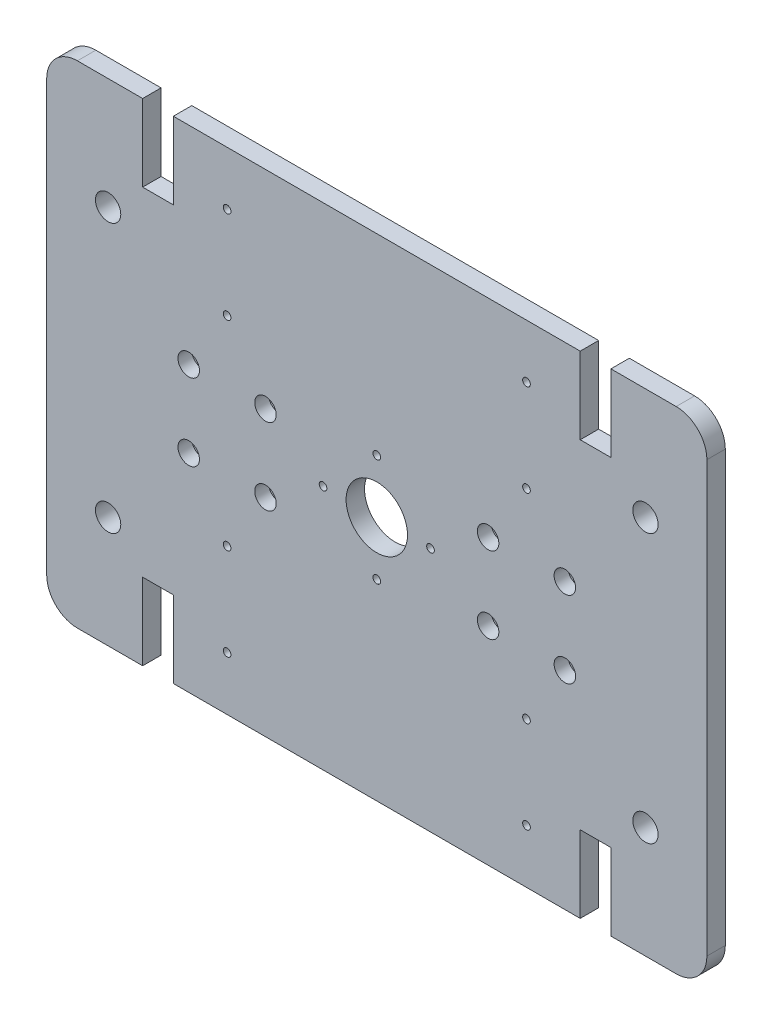
from build123d import *

# Parameters (mm, degrees)
EXTRUDE_1_DEPTH           = 6
HOLE_WIZARD_16_5_16_5_1_D = 16.5
SKETCH_11_R               = 20
CUT_EXTRUDE_1_DEPTH       = 13
HOLE_WIZARD_2_D           = 9
HOLE_WIZARD_2_CBORE_D     = 14
HOLE_WIZARD_2_CBORE_DEPTH = 9
HOLE_WIZARD_M6_1_D        = 5
SKETCH_17_W               = 20
SKETCH_17_H               = 50
CUT_EXTRUDE_2_DEPTH       = 13
HOLE_WIZARD_M6_2_D        = 5
PATTERN_CIRCULAR_1_COUNT  = 4


with BuildPart() as part:
    # 草图1 → 凸台-拉伸1 (new body, symmetric)
    with BuildSketch(Plane.XY):
        with BuildLine():
            Line((-195, -160), (195, -160))
            ThreePointArc((195, -160), (209.142135624, -154.142135624), (215, -140))
            Line((215, -140), (215, 140))
            ThreePointArc((215, 140), (209.142135624, 154.142135624), (195, 160))
            Line((195, 160), (-195, 160))
            ThreePointArc((-195, 160), (-209.142135624, 154.142135624), (-215, 140))
            Line((-215, 140), (-215, -140))
            ThreePointArc((-215, -140), (-209.142135624, -154.142135624), (-195, -160))
        make_face()
    extrude(amount=EXTRUDE_1_DEPTH, both=True)

    # Ø16.5 (16.5) 直径孔1 (through all)
    with Locations(Plane.XY.offset(6)):
        with Locations((-175, 87.5), (175, 87.5), (175, -87.5), (-175, -87.5)):
            Hole(HOLE_WIZARD_16_5_16_5_1_D / 2)

    # 草图11 → 切除-拉伸1 (cut, through all)
    with BuildSketch(Plane.XY.offset(6)):
        Circle(SKETCH_11_R)
    extrude(amount=-CUT_EXTRUDE_1_DEPTH, mode=Mode.SUBTRACT)

    # 打孔尺寸(%根据)内六角圆柱头螺钉的类型2 (through all)
    with Locations(Plane.XY.offset(6)):
        with Locations((-122.5, 25), (-72.5, 25), (-72.5, -25), (-122.5, -25), (72.5, -25), (122.5, -25), (72.5, 25), (122.5, 25)):
            CounterBoreHole(HOLE_WIZARD_2_D / 2, HOLE_WIZARD_2_CBORE_D / 2, HOLE_WIZARD_2_CBORE_DEPTH)

    # M6 螺纹孔1 (through all)
    with Locations(Plane(origin=(0, 0, -6), x_dir=(-1, 0, 0), z_dir=(0, 0, -1))):
        with Locations((-97.5, 65), (-97.5, 125), (-97.5, -125), (-97.5, -65), (97.5, -65), (97.5, -125), (97.5, 125), (97.5, 65)):
            Hole(HOLE_WIZARD_M6_1_D / 2)

    # 草图17 → 切除-拉伸2 (cut, through all)
    with BuildSketch(Plane.XY.offset(6)):
        with Locations((-142.5, 135)):
            Rectangle(SKETCH_17_W, SKETCH_17_H)
        with Locations((142.5, 135)):
            Rectangle(SKETCH_17_W, SKETCH_17_H)
        with Locations((142.5, -135)):
            Rectangle(SKETCH_17_W, SKETCH_17_H)
        with Locations((-142.5, -135)):
            Rectangle(SKETCH_17_W, SKETCH_17_H)
    extrude(amount=-CUT_EXTRUDE_2_DEPTH, mode=Mode.SUBTRACT)

    # M6 螺纹孔2 (through all)
    with Locations(Plane(origin=(0, 35, 6), x_dir=(1, 0, 0), z_dir=(0, 0, 1))):
        with Locations((0, 0)):
            hole_wizard_m6_2 = Hole(HOLE_WIZARD_M6_2_D / 2)

    # 阵列(圆周)1: M6 螺纹孔2 ×4 about axis
    pattern_circular_1_axis = Axis((0, 0, 0), (0, 0, 1))
    for i in range(1, PATTERN_CIRCULAR_1_COUNT):
        add(hole_wizard_m6_2.rotate(pattern_circular_1_axis, i * 360 / PATTERN_CIRCULAR_1_COUNT), mode=Mode.SUBTRACT)


solid = part.part
